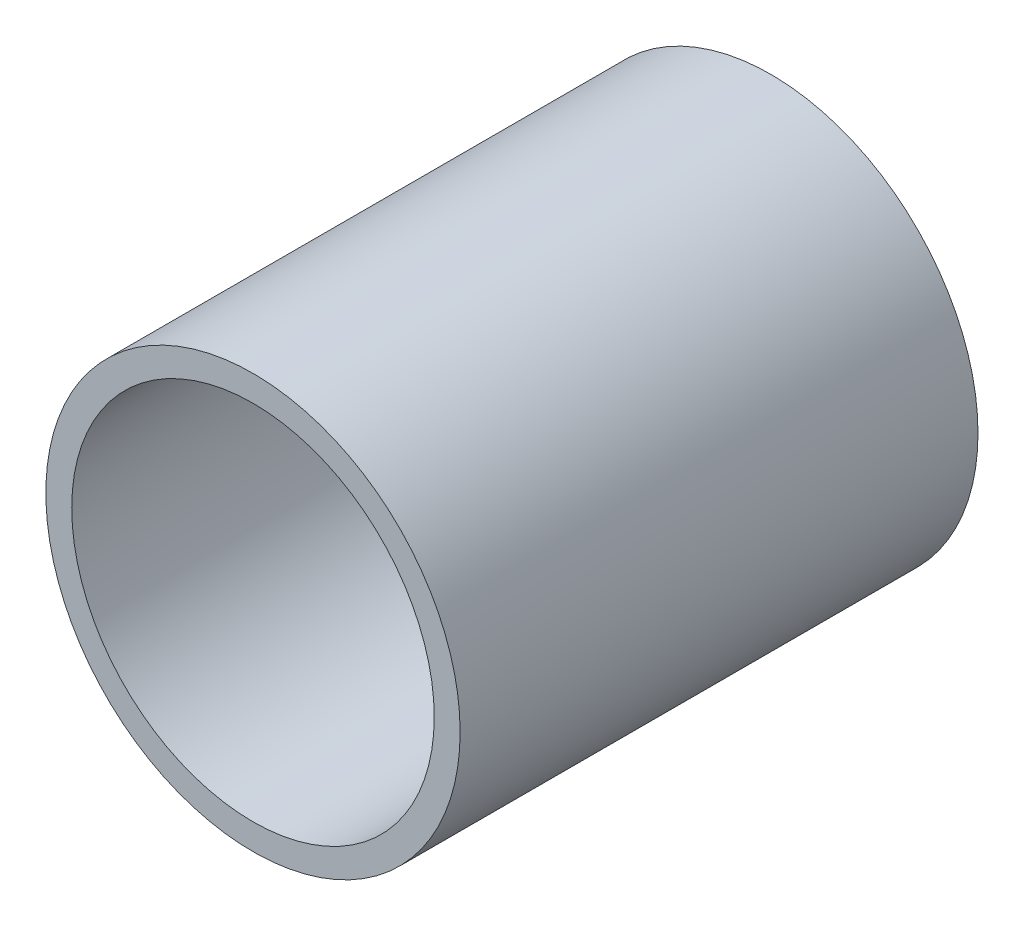
from build123d import *

# Parameters (mm, degrees)
SKETCH1_R           = 4
SKETCH1_R_2         = 3.5
BOSS_EXTRUDE1_DEPTH = 10


with BuildPart() as part:
    # Sketch1 → Boss-Extrude1 (new body)
    with BuildSketch(Plane.XY):
        Circle(SKETCH1_R)
        Circle(SKETCH1_R_2, mode=Mode.SUBTRACT)
    extrude(amount=BOSS_EXTRUDE1_DEPTH)


solid = part.part
